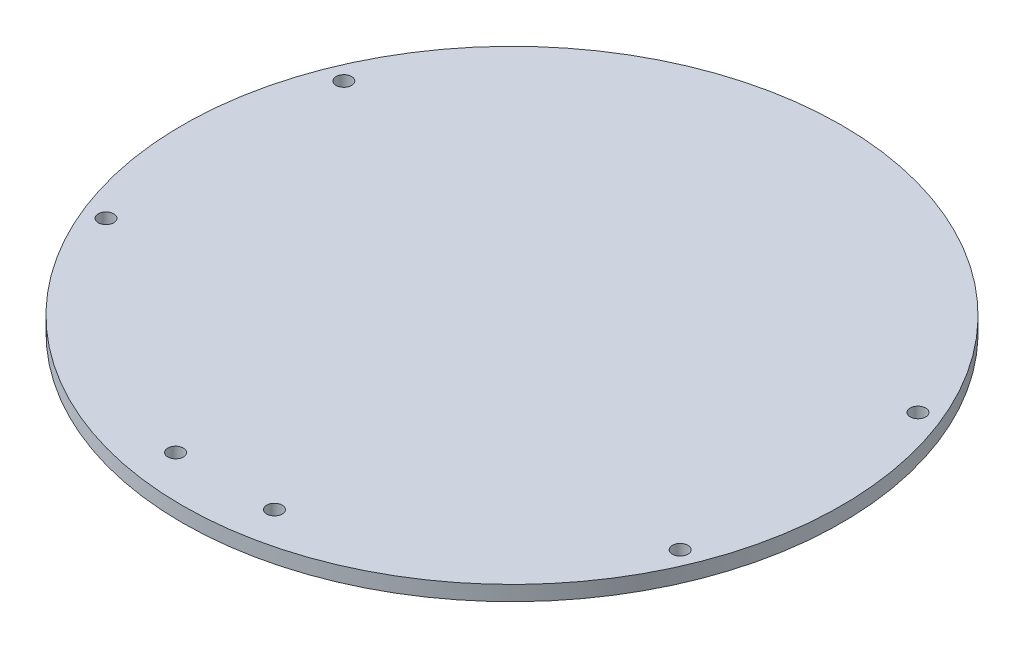
from build123d import *

# Parameters (mm, degrees)
BASE_W_MOTOR_MOUNTS_R  = 70
BOSS_EXTRUDE1_DEPTH    = 3.175
STANDOFFS_TOP_BOTTOM_R = 1.65
CUT_EXTRUDE2_DEPTH     = 3.175


with BuildPart() as part:
    # Base w/ Motor Mounts → Boss-Extrude1 (new body)
    with BuildSketch(Plane(origin=(0, 0, 0), x_dir=(1, 0, 0), z_dir=(0, 1, 0))):
        Circle(BASE_W_MOTOR_MOUNTS_R)
    extrude(amount=BOSS_EXTRUDE1_DEPTH)

    # Standoffs (top / bottom) → Cut-Extrude2 (cut)
    with BuildSketch(Plane(origin=(0, 0, 0), x_dir=(1, 0, 0), z_dir=(0, 1, 0))):
        with Locations((60.976049146, 25.257106536)):
            Circle(STANDOFFS_TOP_BOTTOM_R)
        with Locations((60.976049146, -25.257106536)):
            Circle(STANDOFFS_TOP_BOTTOM_R)
        with Locations((-60.976049146, -25.257106536)):
            Circle(STANDOFFS_TOP_BOTTOM_R)
        with Locations((-60.976049146, 25.257106536)):
            Circle(STANDOFFS_TOP_BOTTOM_R)
        with Locations((10.5, -60.953059289)):
            Circle(STANDOFFS_TOP_BOTTOM_R)
        with Locations((-10.5, -60.953059289)):
            Circle(STANDOFFS_TOP_BOTTOM_R)
    extrude(amount=CUT_EXTRUDE2_DEPTH, mode=Mode.SUBTRACT)


solid = part.part
